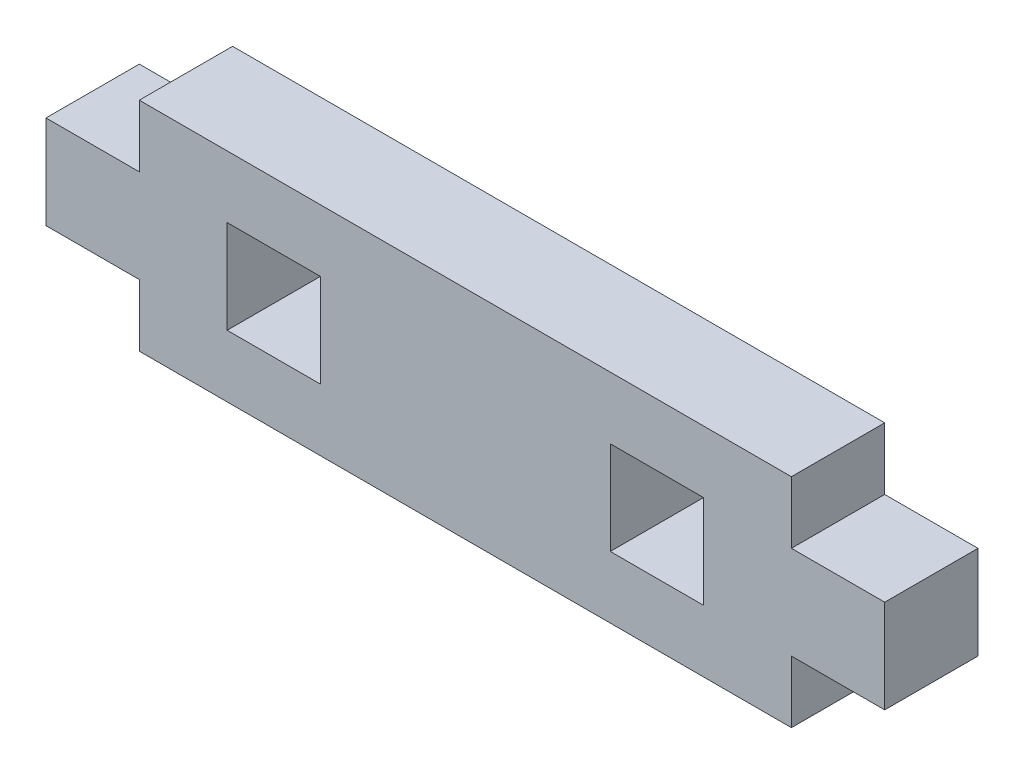
from build123d import *

# Parameters (mm, degrees)
BOSS_EXTRUDE1_DEPTH = 5.15
SKETCH3_W           = 5.15
SKETCH3_H           = 5.15
CUT_EXTRUDE1_DEPTH  = 6.15


with BuildPart() as part:
    # Sketch2 → Boss-Extrude1 (new body)
    with BuildSketch(Plane.XY):
        Polygon((0, 3.425), (0, 8.575), (5.15, 8.575), (5.15, 12), (41.15, 12), (41.15, 8.575), (46.3, 8.575), (46.3, 3.425), (41.15, 3.425), (41.15, 0), (5.15, 0), (5.15, 3.425), align=None)
    extrude(amount=BOSS_EXTRUDE1_DEPTH)

    # Sketch3 → Cut-Extrude1 (cut, through all)
    with BuildSketch(Plane.XY.offset(5.15)):
        with Locations((12.575, 6)):
            Rectangle(SKETCH3_W, SKETCH3_H)
        with Locations((33.725, 6)):
            Rectangle(SKETCH3_W, SKETCH3_H)
    extrude(amount=-CUT_EXTRUDE1_DEPTH, mode=Mode.SUBTRACT)


solid = part.part
